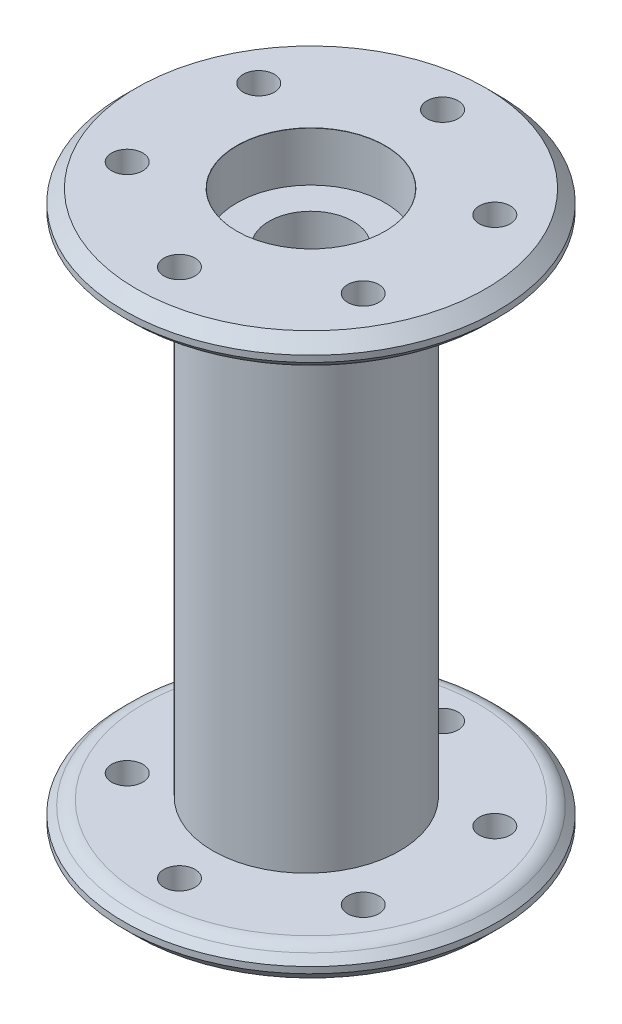
from build123d import *

# Parameters (mm, degrees)
SKETCH1_R                = 15
BOSS_EXTRUDE1_DEPTH      = 40
SKETCH2_R                = 30
BOSS_EXTRUDE2_DEPTH      = 5
CHAMFER1_SIZE            = 2
FILLET1_R                = 3
SKETCH3_R                = 2.5
CUT_EXTRUDE1_DEPTH       = 96
CIRPATTERN2_COUNT        = 6
MIRROR1_COPY_1_SKETCH_R  = 2.5
MIRROR1_COPY_1_DEPTH     = 96
MIRROR1_COPY_2_SKETCH_R  = 2.5
MIRROR1_COPY_2_DEPTH     = 96
MIRROR1_COPY_3_SKETCH_R  = 2.5
MIRROR1_COPY_3_DEPTH     = 96
MIRROR1_COPY_4_SKETCH_R  = 2.5
MIRROR1_COPY_4_DEPTH     = 96
MIRROR1_COPY_5_SKETCH_R  = 2.5
MIRROR1_COPY_5_DEPTH     = 96
CHAMFER1_OF_MIRROR1_SIZE = 2
FILLET1_OF_MIRROR1_R     = 3


with BuildPart() as part:
    # Sketch1 → Boss-Extrude1 (new, symmetric)
    with BuildSketch(Plane(origin=(0, 0, 0), x_dir=(1, 0, 0), z_dir=(0, 1, 0))):
        with Locations(Location((-0.757761668, 0, 0), (0, 0, 270))):
            Circle(SKETCH1_R)
    extrude(amount=BOSS_EXTRUDE1_DEPTH, both=True)

    # Sketch2 → Boss-Extrude2 (add)
    with BuildSketch(Plane(origin=(0, 40, 0), x_dir=(1, 0, 0), z_dir=(0, 1, 0))):
        with Locations(Location((0, 0, 0), (0, 0, 270))):
            Circle(SKETCH2_R)
    boss_extrude2 = extrude(amount=BOSS_EXTRUDE2_DEPTH)

    # Chamfer1
    chamfer1_edges = [part.edges().sort_by_distance(p)[0] for p in [
        (0, 40, -30),
        (0, 45, -30),
    ]]
    chamfer(chamfer1_edges, length=CHAMFER1_SIZE)

    # Fillet1
    fillet1_edges = [part.edges().sort_by_distance(p)[0] for p in [
        (0, 40, -28),
    ]]
    fillet(fillet1_edges, radius=FILLET1_R)

    # Sketch3 → Cut-Extrude1 (cut, through all)
    with BuildSketch(Plane(origin=(0, 45, 0), x_dir=(1, 0, 0), z_dir=(0, 1, 0))):
        with Locations(Location((-0.378880834, 21.5, 0), (0, 0, 270))):
            Circle(SKETCH3_R)
    cut_extrude1 = extrude(amount=-CUT_EXTRUDE1_DEPTH, mode=Mode.SUBTRACT)

    # CirPattern2: Cut-Extrude1 ×6 about axis
    cirpattern2_axis = Axis((0, 0, 0), (0, 1, 0))
    for i in range(1, CIRPATTERN2_COUNT):
        add(cut_extrude1.rotate(cirpattern2_axis, i * 360 / CIRPATTERN2_COUNT), mode=Mode.SUBTRACT)

    # Sketch5 → CBORE for M12 Hex Head Bolt1 (revolve, cut)
    with BuildSketch(Plane(origin=(0, 45, 0), x_dir=(0, 0, 1), z_dir=(1, 0, 0))):
        Polygon((0, 0), (0, 90), (6.75, 90), (6.75, 7.95), (11.89, 7.95), (11.89, 0.025), (11.915, 0), align=None)
    cbore_for_m12_hex_head_bolt1 = revolve(axis=Axis((0, 51.35, 0), (0, -1, 0)), mode=Mode.SUBTRACT)

    # Mirror1: Boss-Extrude2, Cut-Extrude1, CBORE for M12 Hex Head Bolt1 across plane
    add(boss_extrude2.mirror(Plane.ZX))
    add(cut_extrude1.mirror(Plane.ZX), mode=Mode.SUBTRACT)
    add(cbore_for_m12_hex_head_bolt1.mirror(Plane.ZX), mode=Mode.SUBTRACT)

    # Mirror1 copy 1 sketch → Mirror1 copy 1 (cut, through all)
    with BuildSketch(Plane(origin=(0, -45, 0), x_dir=(0.5000000000000001, 0, -0.8660254037844386), z_dir=(0, -1, 0))):
        with Locations((-0.378880834, -21.5)):
            Circle(MIRROR1_COPY_1_SKETCH_R)
    extrude(amount=-MIRROR1_COPY_1_DEPTH, mode=Mode.SUBTRACT)

    # Mirror1 copy 2 sketch → Mirror1 copy 2 (cut, through all)
    with BuildSketch(Plane(origin=(0, -45, 0), x_dir=(-0.4999999999999998, 0, -0.8660254037844387), z_dir=(0, -1, 0))):
        with Locations((-0.378880834, -21.5)):
            Circle(MIRROR1_COPY_2_SKETCH_R)
    extrude(amount=-MIRROR1_COPY_2_DEPTH, mode=Mode.SUBTRACT)

    # Mirror1 copy 3 sketch → Mirror1 copy 3 (cut, through all)
    with BuildSketch(Plane(origin=(0, -45, 0), x_dir=(-1, 0, 0), z_dir=(0, -1, 0))):
        with Locations((-0.378880834, -21.5)):
            Circle(MIRROR1_COPY_3_SKETCH_R)
    extrude(amount=-MIRROR1_COPY_3_DEPTH, mode=Mode.SUBTRACT)

    # Mirror1 copy 4 sketch → Mirror1 copy 4 (cut, through all)
    with BuildSketch(Plane(origin=(0, -45, 0), x_dir=(-0.5000000000000004, 0, 0.8660254037844384), z_dir=(0, -1, 0))):
        with Locations((-0.378880834, -21.5)):
            Circle(MIRROR1_COPY_4_SKETCH_R)
    extrude(amount=-MIRROR1_COPY_4_DEPTH, mode=Mode.SUBTRACT)

    # Mirror1 copy 5 sketch → Mirror1 copy 5 (cut, through all)
    with BuildSketch(Plane(origin=(0, -45, 0), x_dir=(0.5000000000000001, 0, 0.8660254037844386), z_dir=(0, -1, 0))):
        with Locations((-0.378880834, -21.5)):
            Circle(MIRROR1_COPY_5_SKETCH_R)
    extrude(amount=-MIRROR1_COPY_5_DEPTH, mode=Mode.SUBTRACT)

    # Chamfer1 of Mirror1
    chamfer1_of_mirror1_edges = [part.edges().sort_by_distance(p)[0] for p in [
        (0, -40, -30),
        (0, -45, -30),
    ]]
    chamfer(chamfer1_of_mirror1_edges, length=CHAMFER1_OF_MIRROR1_SIZE)

    # Fillet1 of Mirror1
    fillet1_of_mirror1_edges = [part.edges().sort_by_distance(p)[0] for p in [
        (0, -40, -28),
    ]]
    fillet(fillet1_of_mirror1_edges, radius=FILLET1_OF_MIRROR1_R)


solid = part.part
